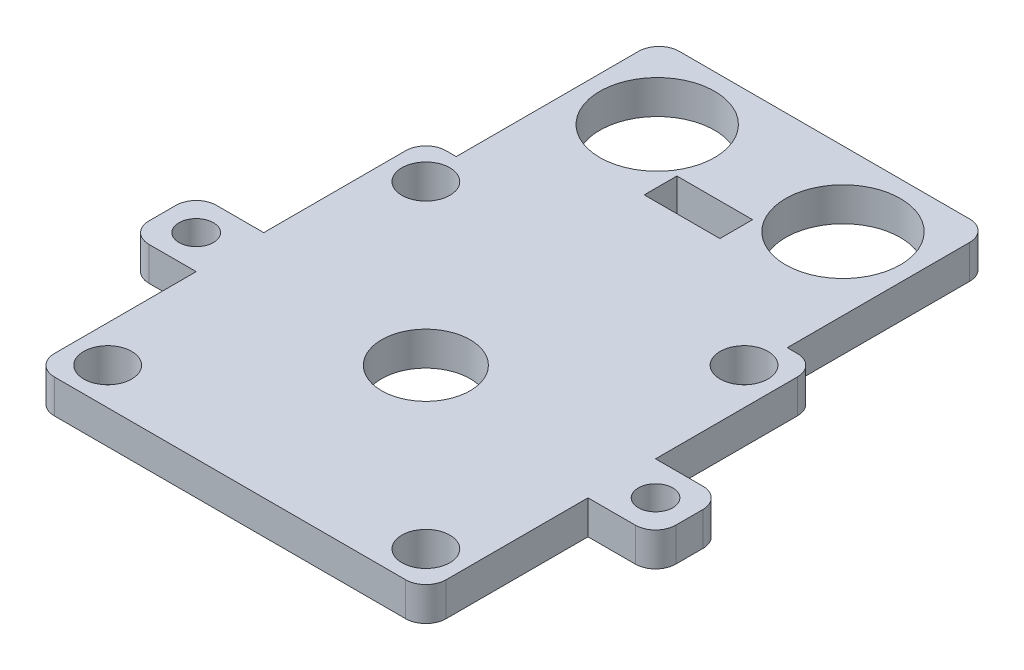
from build123d import *

# Parameters (mm, degrees)
SKETCH1_R           = 21
SKETCH1_R_2         = 20
BOSS_EXTRUDE1_DEPTH = 3.5
SKETCH2_R           = 3.55
SKETCH2_R_2         = 6.55
SKETCH2_R_3         = 2.55
SKETCH2_R_4         = 8.5
SKETCH2_W           = 11.2
SKETCH2_H           = 4.84
BOSS_EXTRUDE2_DEPTH = 5
SKETCH3_W           = 11.2
SKETCH3_H           = 4.84
SKETCH3_W_2         = 49
SKETCH3_H_2         = 8
SKETCH3_R           = 8.5
IGNORE_DEPTH        = 5
SKETCH4_R           = 8.5
SKETCH4_W           = 11.2
SKETCH4_H           = 4.84
CUT_EXTRUDE2_DEPTH  = 6
FILLET1_R           = 3


with BuildPart() as part:
    # Sketch1 → Boss-Extrude1 (new body)
    with BuildSketch(Plane(origin=(0, 0, 0), x_dir=(1, 0, 0), z_dir=(0, 1, 0))):
        Circle(SKETCH1_R)
        Circle(SKETCH1_R_2, mode=Mode.SUBTRACT)
    extrude(amount=BOSS_EXTRUDE1_DEPTH)

    # Sketch2 → Boss-Extrude2 (add)
    with BuildSketch(Plane(origin=(0, 3.5, 0), x_dir=(1, 0, 0), z_dir=(0, 1, 0))):
        Polygon((-29, -5), (-29, -29), (29, -29), (29, -5), (39, -5), (39, 5), (29, 5), (29, 29), (24.5, 29), (24.5, 51), (-24.5, 51), (-24.5, 29), (-29, 29), (-29, 5), (-39, 5), (-39, -5), align=None)
        with Locations((-23.55, -23.55)):
            Circle(SKETCH2_R, mode=Mode.SUBTRACT)
        with Locations((23.55, -23.55)):
            Circle(SKETCH2_R, mode=Mode.SUBTRACT)
        Circle(SKETCH2_R_2, mode=Mode.SUBTRACT)
        with Locations((-23.55, 23.55)):
            Circle(SKETCH2_R, mode=Mode.SUBTRACT)
        with Locations((23.55, 23.55)):
            Circle(SKETCH2_R, mode=Mode.SUBTRACT)
        with Locations((-34, 0)):
            Circle(SKETCH2_R_3, mode=Mode.SUBTRACT)
        with Locations((34, 0)):
            Circle(SKETCH2_R_3, mode=Mode.SUBTRACT)
        with Locations((13.76, 39)):
            Circle(SKETCH2_R_4, mode=Mode.SUBTRACT)
        with Locations((-13.76, 39)):
            Circle(SKETCH2_R_4, mode=Mode.SUBTRACT)
        with Locations((0, 46.28)):
            Rectangle(SKETCH2_W, SKETCH2_H, mode=Mode.SUBTRACT)
    extrude(amount=BOSS_EXTRUDE2_DEPTH)

    # Sketch3 → Ignore (add)
    with BuildSketch(Plane(origin=(0, 3.5, 0), x_dir=(1, 0, 0), z_dir=(0, 1, 0))):
        with Locations((0, 46.28)):
            Rectangle(SKETCH3_W, SKETCH3_H)
        with Locations((0, 55)):
            Rectangle(SKETCH3_W_2, SKETCH3_H_2)
        with Locations((13.76, 39)):
            Circle(SKETCH3_R)
        with Locations((-13.76, 39)):
            Circle(SKETCH3_R)
    extrude(amount=IGNORE_DEPTH)

    # Sketch4 → Cut-Extrude2 (cut, through all)
    with BuildSketch(Plane(origin=(0, 3.5, 0), x_dir=(1, 0, 0), z_dir=(0, 1, 0))):
        with Locations((-13.75, 48)):
            Circle(SKETCH4_R)
        with Locations((13.75, 48)):
            Circle(SKETCH4_R)
        with Locations((-0.079148889, 40.42)):
            Rectangle(SKETCH4_W, SKETCH4_H)
    extrude(amount=CUT_EXTRUDE2_DEPTH, mode=Mode.SUBTRACT)

    # Fillet1
    fillet1_edges = [part.edges().sort_by_distance(p)[0] for p in [
        (-29, 6, 29),
        (29, 6, 29),
        (39, 6, 5),
        (39, 6, -5),
        (29, 6, -29),
        (-29, 6, -29),
        (-39, 6, -5),
        (-39, 6, 5),
        (24.5, 6, -59),
        (-24.5, 6, -59),
    ]]
    fillet(fillet1_edges, radius=FILLET1_R)


solid = part.part
